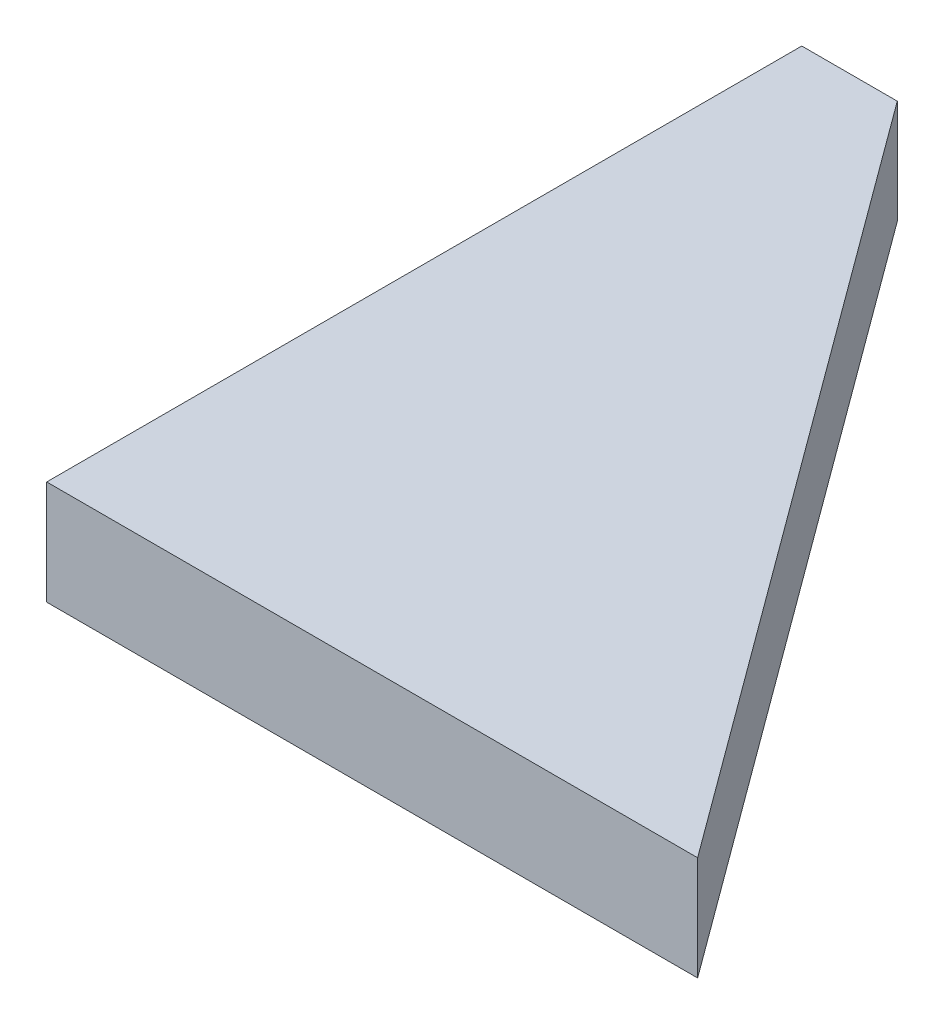
from build123d import *

# Parameters (mm, degrees)
EXTRUDE_1_DEPTH = 4


with BuildPart() as part:
    # Эскиз1 → Бобышка-Вытянуть1 (new body)
    with BuildSketch(Plane(origin=(0, 0, 0), x_dir=(1, 0, 0), z_dir=(0, 1, 0))):
        Polygon((0, 1.475038137), (0, 30.475038137), (3.668679253, 30.475038137), (25, 1.475038137), align=None)
    extrude(amount=EXTRUDE_1_DEPTH)


solid = part.part
